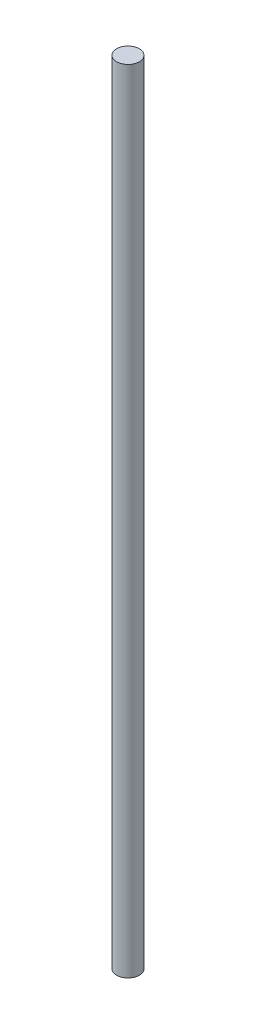
from build123d import *

# Parameters (mm, degrees)
SKETCH2_R           = 2
BOSS_EXTRUDE1_DEPTH = 140


with BuildPart() as part:
    # Sketch2 → Boss-Extrude1 (new body)
    with BuildSketch(Plane(origin=(0, 0, 0), x_dir=(1, 0, 0), z_dir=(0, 1, 0))):
        Circle(SKETCH2_R)
    extrude(amount=BOSS_EXTRUDE1_DEPTH)


solid = part.part
